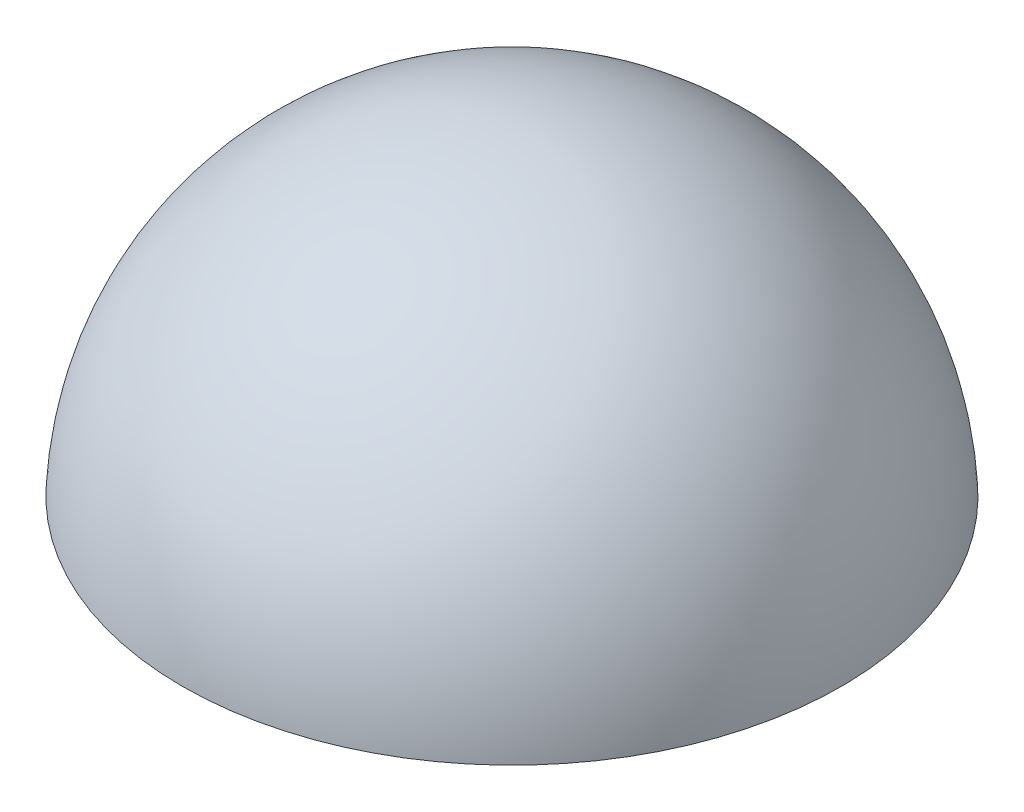
from build123d import *

# Parameters (mm, degrees)
REVOLVE1_ANGLE     = 180
SKETCH2_R          = 44.45
CUT_EXTRUDE1_DEPTH = 2


with BuildPart() as part:
    # Sketch1 → Revolve1 (revolve)
    with BuildSketch(Plane(origin=(0, 0, 0), x_dir=(1, 0, 0), z_dir=(0, 1, 0))):
        with BuildLine():
            ThreePointArc((0, 44.45), (-44.45, 0), (0, -44.45))
            Line((0, -44.45), (0, -42.45))
            ThreePointArc((0, -42.45), (-42.45, 0), (0, 42.45))
            Line((0, 42.45), (0, 44.45))
        make_face()
    revolve(axis=Axis((0, 0, 44.45), (0, 0, -1)), revolution_arc=REVOLVE1_ANGLE)

    # Sketch2 → Cut-Extrude1 (cut)
    with BuildSketch(Plane(origin=(0, 0, 0), x_dir=(1, 0, 0), z_dir=(0, 1, 0))):
        Circle(SKETCH2_R)
    extrude(amount=CUT_EXTRUDE1_DEPTH, mode=Mode.SUBTRACT)


solid = part.part
